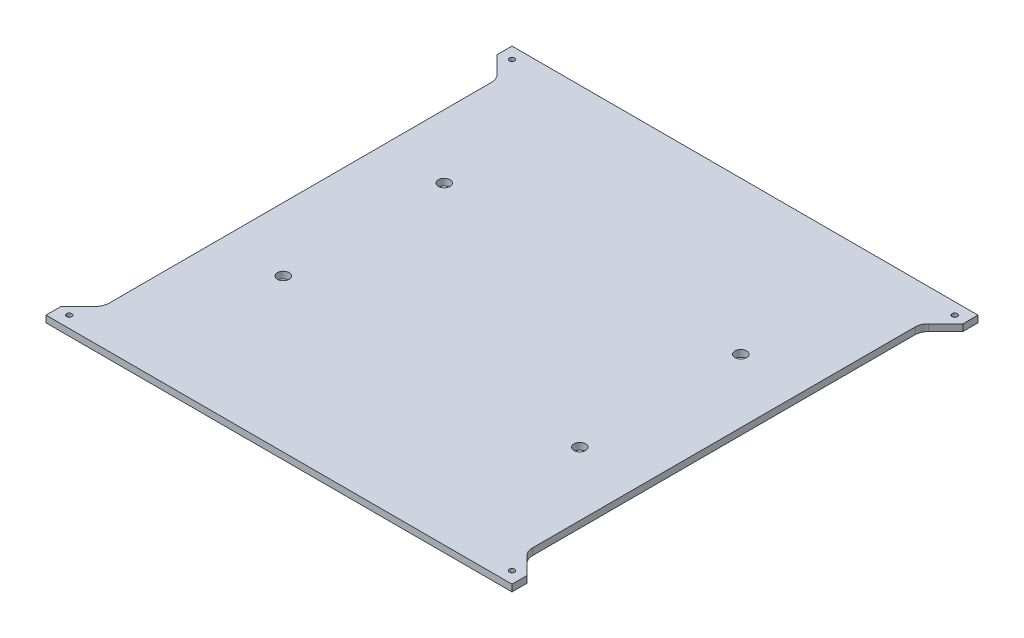
from build123d import *

# Parameters (mm, degrees)
SKETCH1_W             = 220
SKETCH1_H             = 220
BOSS_EXTRUDE1_DEPTH   = 3.175
M3X0_5_TAPPED_HOLE1_D = 2.5
SKETCH4_R             = 2.75
CUT_EXTRUDE1_DEPTH    = 4.175
CUT_EXTRUDE2_DEPTH    = 4.175


with BuildPart() as part:
    # Sketch1 → Boss-Extrude1 (new body)
    with BuildSketch(Plane(origin=(0, 0, 0), x_dir=(1, 0, 0), z_dir=(0, 1, 0))):
        Rectangle(SKETCH1_W, SKETCH1_H)
    extrude(amount=BOSS_EXTRUDE1_DEPTH)

    # M3x0.5 Tapped Hole1 (through all)
    with Locations(Plane(origin=(0, 3.175, 0), x_dir=(-1, 0, 0), z_dir=(0, 1, 0))):
        with Locations((104.5, -104.5), (-104.5, -104.5), (-104.5, 104.5), (104.5, 104.5)):
            Hole(M3X0_5_TAPPED_HOLE1_D / 2)

    # Sketch4 → Cut-Extrude1 (cut, through all)
    with BuildSketch(Plane(origin=(0, 3.175, 0), x_dir=(1, 0, 0), z_dir=(0, 1, 0))):
        with Locations(Location((-70, 38, 0), (0, 0, 270))):  # turned: the seam where the file's is
            Circle(SKETCH4_R)
        with Locations(Location((-70, -38, 0), (0, 0, 270))):  # turned: the seam where the file's is
            Circle(SKETCH4_R)
        with Locations(Location((70, -38, 0), (0, 0, 270))):  # turned: the seam where the file's is
            Circle(SKETCH4_R)
        with Locations(Location((70, 38, 0), (0, 0, 270))):  # turned: the seam where the file's is
            Circle(SKETCH4_R)
    extrude(amount=-CUT_EXTRUDE1_DEPTH, mode=Mode.SUBTRACT)

    # Sketch5 → Cut-Extrude2 (cut, through all)
    with BuildSketch(Plane(origin=(0, 3.175, 0), x_dir=(1, 0, 0), z_dir=(0, 1, 0))):
        with BuildLine():
            Line((-110, 102.928932188), (-110, -102.928932188))
            Line((-110, -102.928932188), (-101.859871939, -94.788804128))
            ThreePointArc((-101.859871939, -94.788804128), (-100.483364969, -92.728715863), (-100, -90.298676067))
            Line((-100, -90.298676067), (-100, 90.298676067))
            ThreePointArc((-100, 90.298676067), (-100.483364969, 92.728715863), (-101.859871939, 94.788804128))
            Line((-101.859871939, 94.788804128), (-110, 102.928932188))
        make_face()
        with BuildLine():
            Line((110, 102.928932188), (101.859871939, 94.788804128))
            ThreePointArc((101.859871939, 94.788804128), (100.483364969, 92.728715863), (100, 90.298676067))
            Line((100, 90.298676067), (100, -90.298676067))
            ThreePointArc((100, -90.298676067), (100.483364969, -92.728715863), (101.859871939, -94.788804128))
            Line((101.859871939, -94.788804128), (110, -102.928932188))
            Line((110, -102.928932188), (110, 102.928932188))
        make_face()
    extrude(amount=-CUT_EXTRUDE2_DEPTH, mode=Mode.SUBTRACT)


solid = part.part
